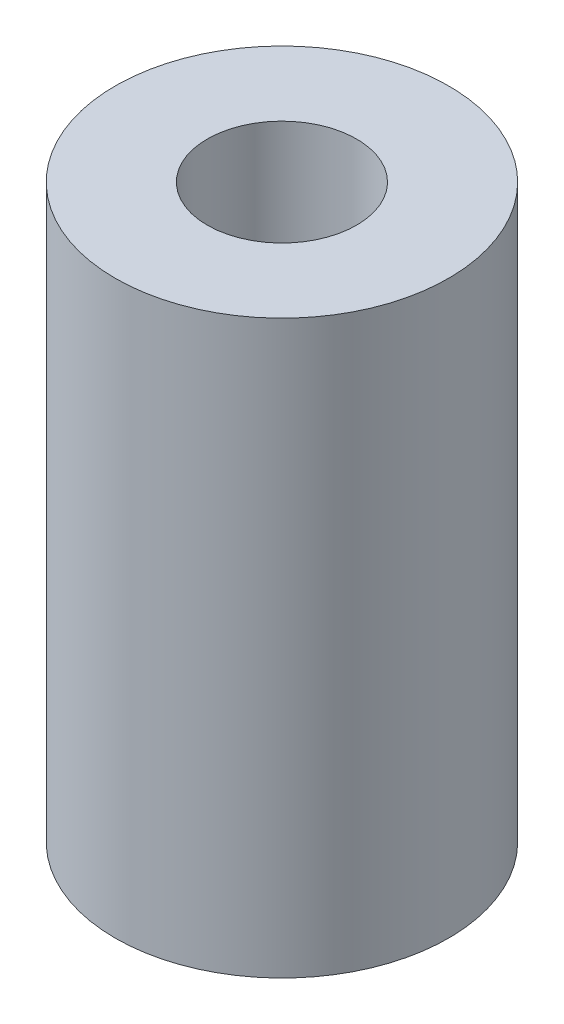
from build123d import *

# Parameters (mm, degrees)
SKETCH1_R           = 7.7
SKETCH1_R_2         = 3.45
BOSS_EXTRUDE1_DEPTH = 26.4


with BuildPart() as part:
    # Sketch1 → Boss-Extrude1 (new body)
    with BuildSketch(Plane(origin=(0, 0, 0), x_dir=(1, 0, 0), z_dir=(0, 1, 0))):
        Circle(SKETCH1_R)
        Circle(SKETCH1_R_2, mode=Mode.SUBTRACT)
    extrude(amount=BOSS_EXTRUDE1_DEPTH)


solid = part.part
